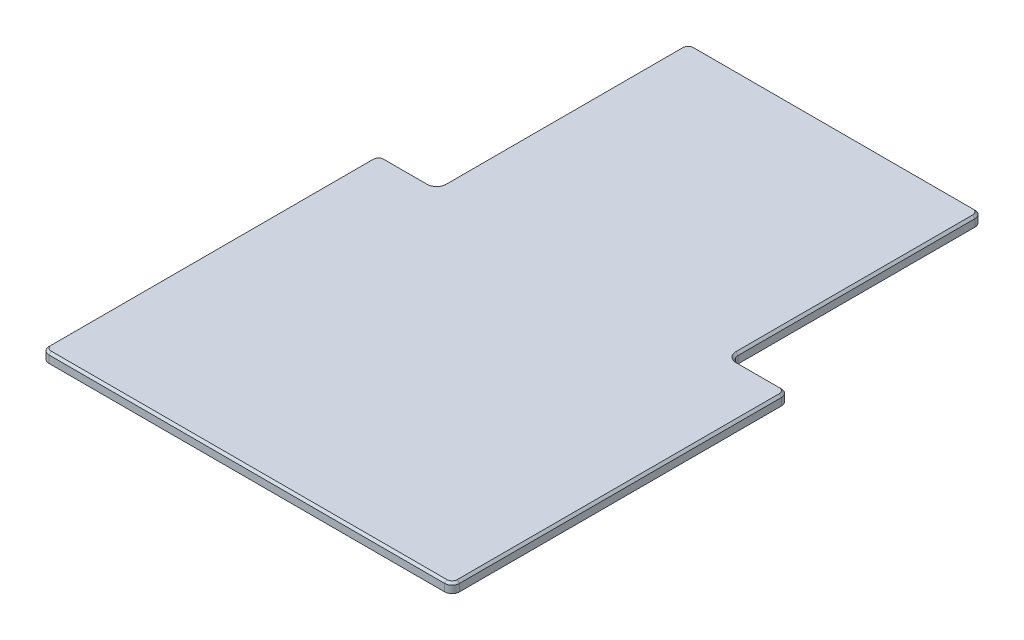
from build123d import *

# Parameters (mm, degrees)
BOSS_EXTRUDE2_DEPTH = 13
CHAMFER2_SIZE       = 3


with BuildPart() as part:
    # Sketch1 → Boss-Extrude2 (new body)
    with BuildSketch(Plane(origin=(0, 0, 0), x_dir=(1, 0, 0), z_dir=(0, 1, 0))):
        with BuildLine():
            Line((10, 0), (548, 0))
            ThreePointArc((548, 0), (555.071067812, 2.928932188), (558, 10))
            Line((558, 10), (558, 448))
            ThreePointArc((558, 448), (555.071067812, 455.071067812), (548, 458))
            Line((548, 458), (489, 458))
            ThreePointArc((489, 458), (481.928932188, 460.928932188), (479, 468))
            Line((479, 468), (479, 790))
            ThreePointArc((479, 790), (476.071067812, 797.071067812), (469, 800))
            Line((469, 800), (89, 800))
            ThreePointArc((89, 800), (81.928932188, 797.071067812), (79, 790))
            Line((79, 790), (79, 468))
            ThreePointArc((79, 468), (76.071067812, 460.928932188), (69, 458))
            Line((69, 458), (10, 458))
            ThreePointArc((10, 458), (2.928932188, 455.071067812), (0, 448))
            Line((0, 448), (0, 10))
            ThreePointArc((0, 10), (2.928932188, 2.928932188), (10, 0))
        make_face()
    extrude(amount=BOSS_EXTRUDE2_DEPTH)

    # Chamfer2
    chamfer2_edges = [part.edges().sort_by_distance(p)[0] for p in [
        (81.928932188, 13, -797.071067812),
        (79, 13, -629),
        (76.071067812, 13, -460.928932188),
        (39.5, 13, -458),
        (2.928932188, 13, -455.071067812),
        (0, 13, -229),
        (2.928932188, 13, -2.928932188),
        (279, 13, 0),
        (555.071067812, 13, -2.928932188),
        (558, 13, -229),
        (476.071067812, 13, -797.071067812),
        (555.071067812, 13, -455.071067812),
        (518.5, 13, -458),
        (481.928932188, 13, -460.928932188),
        (479, 13, -629),
        (279, 13, -800),
    ]]
    chamfer(chamfer2_edges, length=CHAMFER2_SIZE)


solid = part.part
